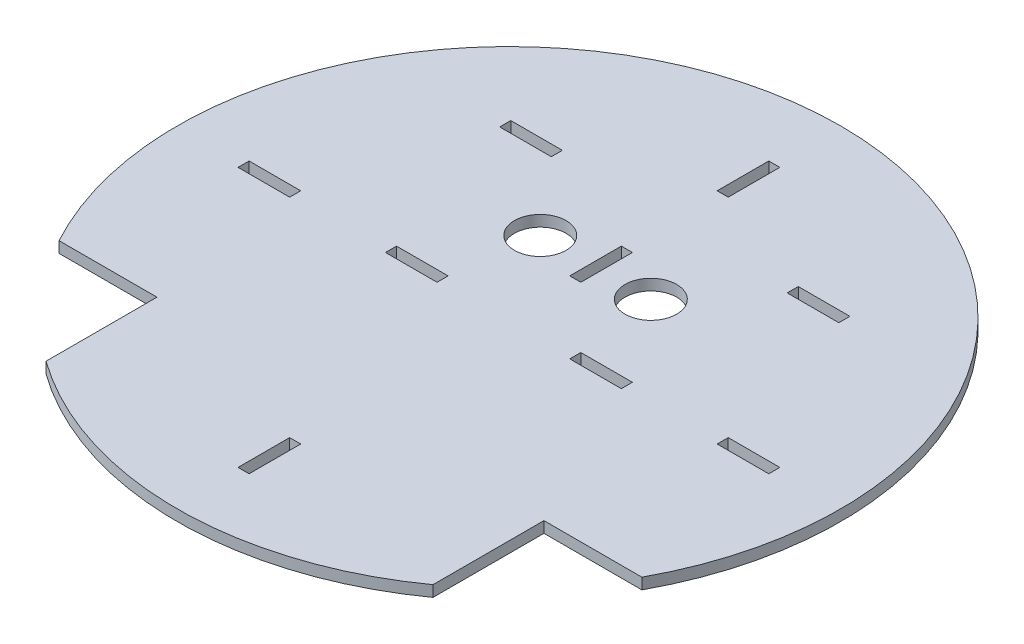
from build123d import *

# Parameters (mm, degrees)
SKETCH1_R               = 90
BOSS_EXTRUDE1_DEPTH     = 3
CUT_EXTRUDE1_DEPTH      = 1
CUT_EXTRUDE1_DEPTH_BACK = 3
CUT_EXTRUDE2_DEPTH      = 1
CUT_EXTRUDE2_DEPTH_BACK = 3
SKETCH5_W               = 3
SKETCH5_H               = 14
CUT_EXTRUDE4_DEPTH      = 3
SKETCH6_W               = 3
SKETCH6_H               = 14
CUT_EXTRUDE5_DEPTH      = 3
SKETCH8_W               = 3
SKETCH8_H               = 14
CUT_EXTRUDE7_DEPTH      = 3
SKETCH9_W               = 14
SKETCH9_H               = 3
CUT_EXTRUDE8_DEPTH      = 3
SKETCH10_W              = 14
SKETCH10_H              = 3
CUT_EXTRUDE9_DEPTH      = 3
SKETCH11_W              = 14
SKETCH11_H              = 3
CUT_EXTRUDE10_DEPTH     = 3
SKETCH12_W              = 14
SKETCH12_H              = 3
CUT_EXTRUDE11_DEPTH     = 3
SKETCH13_W              = 14
SKETCH13_H              = 3
CUT_EXTRUDE12_DEPTH     = 3
SKETCH14_W              = 14
SKETCH14_H              = 3
CUT_EXTRUDE13_DEPTH     = 3
SKETCH15_R              = 7
CUT_EXTRUDE14_DEPTH     = 3


with BuildPart() as part:
    # Sketch1 → Boss-Extrude1 (new body)
    with BuildSketch(Plane(origin=(0, 0, 0), x_dir=(1, 0, 0), z_dir=(0, 1, 0))):
        Circle(SKETCH1_R)
    extrude(amount=BOSS_EXTRUDE1_DEPTH)

    # Sketch2 → Cut-Extrude1 (cut, two sides)
    with BuildSketch(Plane(origin=(0, 3, 0), x_dir=(1, 0, 0), z_dir=(0, 1, 0))) as cut_extrude1_sk:
        Polygon((-52.5, -516.266848974), (-52.5, -73.100957586), (-52.5, -43), (-79.063265807, -43), (-522.229157195, -43), (-1151.30715458, -667.375610001), (-681.577997385, -1140.642458975), align=None)
    extrude(amount=CUT_EXTRUDE1_DEPTH, mode=Mode.SUBTRACT)
    extrude(cut_extrude1_sk.sketch, amount=-CUT_EXTRUDE1_DEPTH_BACK, mode=Mode.SUBTRACT)

    # Sketch3 → Cut-Extrude2 (cut, two sides)
    with BuildSketch(Plane(origin=(0, 3, 0), x_dir=(1, 0, 0), z_dir=(0, 1, 0))) as cut_extrude2_sk:
        Polygon((52.5, -516.266848974), (52.5, -73.100957586), (52.5, -43), (79.063265807, -43), (522.229157195, -43), (1151.30715458, -667.375610001), (681.577997385, -1140.642458975), align=None)
    extrude(amount=CUT_EXTRUDE2_DEPTH, mode=Mode.SUBTRACT)
    extrude(cut_extrude2_sk.sketch, amount=-CUT_EXTRUDE2_DEPTH_BACK, mode=Mode.SUBTRACT)

    # Sketch5 → Cut-Extrude4 (cut)
    with BuildSketch(Plane(origin=(0, 3, 0), x_dir=(1, 0, 0), z_dir=(0, 1, 0))):
        with Locations((0, 25)):
            Rectangle(SKETCH5_W, SKETCH5_H)
    extrude(amount=-CUT_EXTRUDE4_DEPTH, mode=Mode.SUBTRACT)

    # Sketch6 → Cut-Extrude5 (cut)
    with BuildSketch(Plane(origin=(0, 3, 0), x_dir=(1, 0, 0), z_dir=(0, 1, 0))):
        with Locations((0, 65)):
            Rectangle(SKETCH6_W, SKETCH6_H)
    extrude(amount=-CUT_EXTRUDE5_DEPTH, mode=Mode.SUBTRACT)

    # Sketch8 → Cut-Extrude7 (cut)
    with BuildSketch(Plane(origin=(0, 3, 0), x_dir=(1, 0, 0), z_dir=(0, 1, 0))):
        with Locations((0, -65)):
            Rectangle(SKETCH8_W, SKETCH8_H)
    extrude(amount=-CUT_EXTRUDE7_DEPTH, mode=Mode.SUBTRACT)

    # Sketch9 → Cut-Extrude8 (cut)
    with BuildSketch(Plane(origin=(0, 3, 0), x_dir=(1, 0, 0), z_dir=(0, 1, 0))):
        with Locations((-25, 0)):
            Rectangle(SKETCH9_W, SKETCH9_H)
    extrude(amount=-CUT_EXTRUDE8_DEPTH, mode=Mode.SUBTRACT)

    # Sketch10 → Cut-Extrude9 (cut)
    with BuildSketch(Plane(origin=(0, 3, 0), x_dir=(1, 0, 0), z_dir=(0, 1, 0))):
        with Locations((-65, 0)):
            Rectangle(SKETCH10_W, SKETCH10_H)
    extrude(amount=-CUT_EXTRUDE9_DEPTH, mode=Mode.SUBTRACT)

    # Sketch11 → Cut-Extrude10 (cut)
    with BuildSketch(Plane(origin=(0, 3, 0), x_dir=(1, 0, 0), z_dir=(0, 1, 0))):
        with Locations((25, 0)):
            Rectangle(SKETCH11_W, SKETCH11_H)
    extrude(amount=-CUT_EXTRUDE10_DEPTH, mode=Mode.SUBTRACT)

    # Sketch12 → Cut-Extrude11 (cut)
    with BuildSketch(Plane(origin=(0, 3, 0), x_dir=(1, 0, 0), z_dir=(0, 1, 0))):
        with Locations((65, 0)):
            Rectangle(SKETCH12_W, SKETCH12_H)
    extrude(amount=-CUT_EXTRUDE11_DEPTH, mode=Mode.SUBTRACT)

    # Sketch13 → Cut-Extrude12 (cut)
    with BuildSketch(Plane(origin=(0, 3, 0), x_dir=(1, 0, 0), z_dir=(0, 1, 0))):
        with Locations((-39, 45)):
            Rectangle(SKETCH13_W, SKETCH13_H)
    extrude(amount=-CUT_EXTRUDE12_DEPTH, mode=Mode.SUBTRACT)

    # Sketch14 → Cut-Extrude13 (cut)
    with BuildSketch(Plane(origin=(0, 3, 0), x_dir=(1, 0, 0), z_dir=(0, 1, 0))):
        with Locations((39, 45)):
            Rectangle(SKETCH14_W, SKETCH14_H)
    extrude(amount=-CUT_EXTRUDE13_DEPTH, mode=Mode.SUBTRACT)

    # Sketch15 → Cut-Extrude14 (cut)
    with BuildSketch(Plane(origin=(0, 3, 0), x_dir=(1, 0, 0), z_dir=(0, 1, 0))):
        with Locations((-15, 23.5)):
            Circle(SKETCH15_R)
        with Locations((15, 23.5)):
            Circle(SKETCH15_R)
    extrude(amount=-CUT_EXTRUDE14_DEPTH, mode=Mode.SUBTRACT)


solid = part.part
